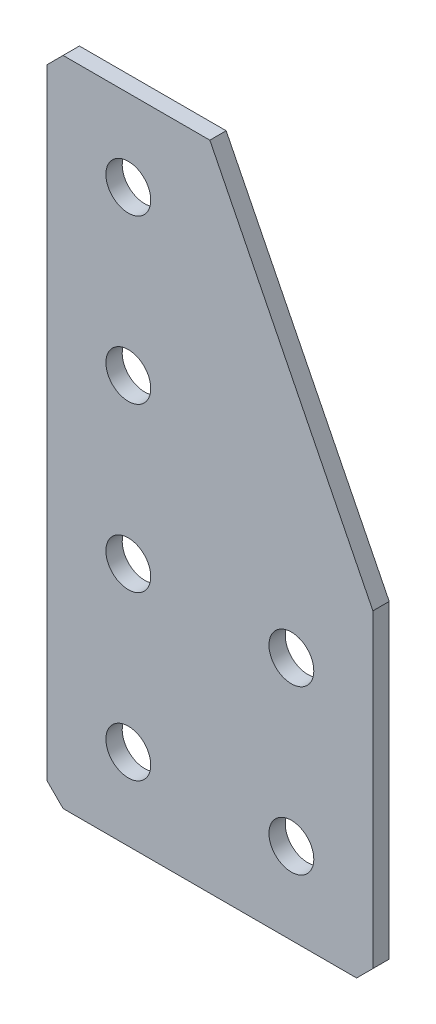
from build123d import *

# Parameters (mm, degrees)
EXTRUDE_1_DEPTH   = 2
HOLE_WIZARD_M51_D = 5.5
CHAMFER_1_SIZE    = 2


with BuildPart() as part:
    # Эскиз1 → Бобышка-Вытянуть1 (new body)
    with BuildSketch(Plane(origin=(0, 0, 0), x_dir=(1, 0, 0), z_dir=(0, 0, -1))):
        Polygon((0, 0), (0, 80), (40, 80), (40, 40), (20, 0), align=None)
    extrude(amount=EXTRUDE_1_DEPTH)

    # Отверстие с зазором M51 (through all)
    with Locations(Plane(origin=(0, 0, -2), x_dir=(1, 0, 0), z_dir=(0, 0, -1))):
        with Locations((10, 70), (10, 50), (10, 30), (10, 10), (30, 70), (30, 50)):
            Hole(HOLE_WIZARD_M51_D / 2)

    # Фаска1
    chamfer_1_edges = [part.edges().sort_by_distance(p)[0] for p in [
        (0, 0, -1),
        (0, -80, -1),
        (40, -80, -1),
    ]]
    chamfer(chamfer_1_edges, length=CHAMFER_1_SIZE)


solid = part.part
